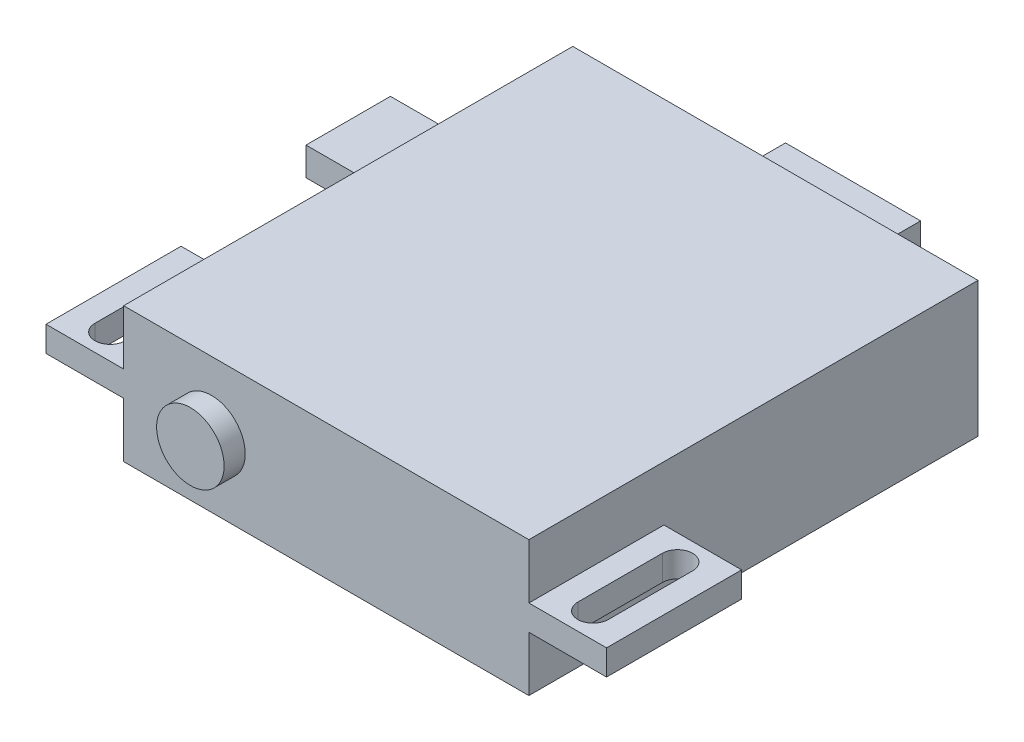
from build123d import *

# Parameters (mm, degrees)
SKETCH1_W           = 30.48
SKETCH1_H           = 33.782
BOSS_EXTRUDE1_DEPTH = 5.08
SKETCH2_R           = 2.54
BOSS_EXTRUDE2_DEPTH = 1.5875
SKETCH3_W           = 5.842
SKETCH3_H           = 10.16
BOSS_EXTRUDE3_DEPTH = 0.9525
SKETCH4_W           = 10.16
SKETCH4_H           = 5.842
BOSS_EXTRUDE4_DEPTH = 0.9525
SKETCH5_W           = 6.35
SKETCH5_H           = 2.131234452
BOSS_EXTRUDE5_DEPTH = 7.62


with BuildPart() as part:
    # Sketch1 → Boss-Extrude1 (new body, symmetric)
    with BuildSketch(Plane(origin=(0, 0, 0), x_dir=(1, 0, 0), z_dir=(0, 1, 0))):
        Rectangle(SKETCH1_W, SKETCH1_H)
    extrude(amount=BOSS_EXTRUDE1_DEPTH, both=True)

    # Sketch2 → Boss-Extrude2 (add, symmetric)
    with BuildSketch(Plane.XY.offset(16.891)):
        with Locations((-8.636, 0)):
            Circle(SKETCH2_R)
    extrude(amount=BOSS_EXTRUDE2_DEPTH, both=True)

    # Sketch3 → Boss-Extrude3 (add, symmetric)
    with BuildSketch(Plane(origin=(0, 0, 0), x_dir=(1, 0, 0), z_dir=(0, 1, 0))):
        with Locations((18.161, -11.811)):
            Rectangle(SKETCH3_W, SKETCH3_H)
        with BuildLine():
            Line((19.304, -8.636), (19.304, -14.986))
            ThreePointArc((19.304, -14.986), (18.161, -16.129), (17.018, -14.986))
            Line((17.018, -14.986), (17.018, -8.636))
            ThreePointArc((17.018, -8.636), (18.161, -7.493), (19.304, -8.636))
        make_face(mode=Mode.SUBTRACT)
    boss_extrude3 = extrude(amount=BOSS_EXTRUDE3_DEPTH, both=True)

    # Mirror1: Boss-Extrude3 across plane
    add(boss_extrude3.mirror(Plane(origin=(0, 0, 0), x_dir=(0, 0, 1), z_dir=(1, 0, 0))))

    # Sketch4 → Boss-Extrude4 (add, symmetric)
    with BuildSketch(Plane(origin=(0, 0, 0), x_dir=(1, 0, 0), z_dir=(0, 1, 0))):
        with Locations((0, 19.812)):
            Rectangle(SKETCH4_W, SKETCH4_H)
        with BuildLine():
            Line((-3.175, 20.955), (3.175, 20.955))
            ThreePointArc((3.175, 20.955), (4.318, 19.812), (3.175, 18.669))
            Line((3.175, 18.669), (-3.175, 18.669))
            ThreePointArc((-3.175, 18.669), (-4.318, 19.812), (-3.175, 20.955))
        make_face(mode=Mode.SUBTRACT)
    extrude(amount=BOSS_EXTRUDE4_DEPTH, both=True)

    # Sketch5 → Boss-Extrude5 (add)
    with BuildSketch(Plane.ZY.offset(15.24)):
        with Locations((-7.62, 0)):
            Rectangle(SKETCH5_W, SKETCH5_H)
    extrude(amount=BOSS_EXTRUDE5_DEPTH)


solid = part.part
